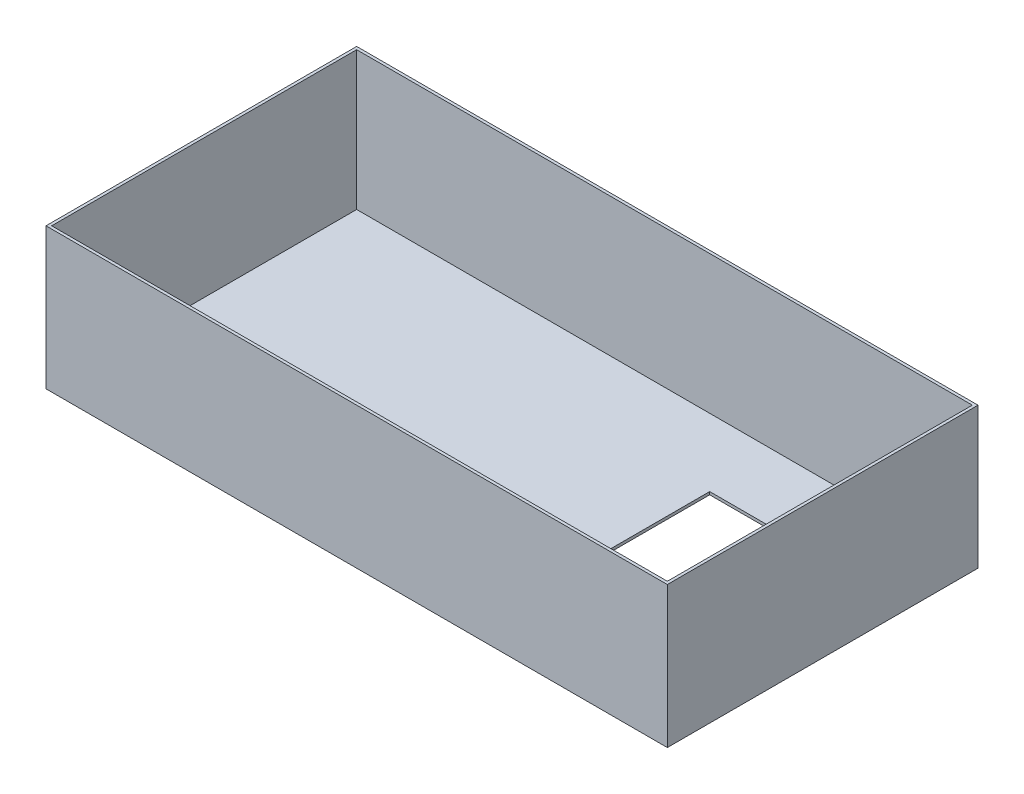
from build123d import *

# Parameters (mm, degrees)
SKETCH1_W          = 2200
SKETCH1_H          = 1100
EXTRUDE1_DEPTH     = 500
SHELL1_T           = -10
SKETCH2_W          = 600
SKETCH2_H          = 600
CUT_EXTRUDE1_DEPTH = 400


with BuildPart() as part:
    # Sketch1 → Extrude1 (new body)
    with BuildSketch(Plane(origin=(0, 0, 0), x_dir=(1, 0, 0), z_dir=(0, 1, 0))):
        with Locations((-1100, 550)):
            Rectangle(SKETCH1_W, SKETCH1_H)
    extrude(amount=EXTRUDE1_DEPTH)

    # Shell1
    shell1_openings = [part.faces().sort_by_distance(p)[0] for p in [
        (-1100, 500, -550),
    ]]
    offset(amount=SHELL1_T, openings=shell1_openings, kind=Kind.INTERSECTION)

    # Sketch2 → Cut-Extrude1 (cut)
    with BuildSketch(Plane.XZ):
        with Locations((-400, -550)):
            Rectangle(SKETCH2_W, SKETCH2_H)
    extrude(amount=-CUT_EXTRUDE1_DEPTH, mode=Mode.SUBTRACT)


solid = part.part
